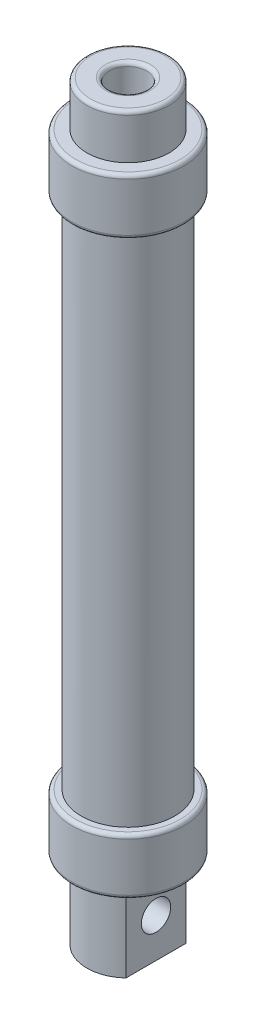
from build123d import *

# Parameters (mm, degrees)
SKETCH5_R                = 12.5
SKETCH5_R_2              = 10.5
BOSS_EXTRUDE2_DEPTH      = 140
SKETCH6_R                = 15
SKETCH6_R_2              = 11.543764588
BOSS_EXTRUDE3_DEPTH      = 14
BOSS_EXTRUDE3_DEPTH_BACK = 1
SKETCH7_R                = 15
SKETCH7_R_2              = 11.552767092
BOSS_EXTRUDE4_DEPTH      = 14
BOSS_EXTRUDE4_DEPTH_BACK = 1
FILLET1_R                = 1
FILLET2_R                = 1
FILLET3_R                = 1
FILLET4_R                = 1
SKETCH8_R                = 12.593226889
BOSS_EXTRUDE5_DEPTH      = 1
SKETCH9_R                = 12.737258032
BOSS_EXTRUDE6_DEPTH      = 1
SKETCH10_R               = 11
BOSS_EXTRUDE7_DEPTH      = 21
CUT_EXTRUDE1_DEPTH       = 21
SKETCH12_R               = 3.935
CUT_EXTRUDE2_DEPTH       = 23.5000001
SKETCH13_R               = 11
BOSS_EXTRUDE8_DEPTH      = 12
SKETCH14_R               = 5
CUT_EXTRUDE3_DEPTH       = 20
FILLET5_R                = 1
FILLET6_R                = 1


with BuildPart() as part:
    # Sketch5 → Boss-Extrude2 (new body)
    with BuildSketch(Plane(origin=(0, 0, 0), x_dir=(1, 0, 0), z_dir=(0, 1, 0))):
        Circle(SKETCH5_R)
        Circle(SKETCH5_R_2, mode=Mode.SUBTRACT)
    extrude(amount=BOSS_EXTRUDE2_DEPTH)

    # Sketch6 → Boss-Extrude3 (add, two sides)
    with BuildSketch(Plane(origin=(0, 140, 0), x_dir=(1, 0, 0), z_dir=(0, 1, 0))) as boss_extrude3_sk:
        Circle(SKETCH6_R)
        Circle(SKETCH6_R_2, mode=Mode.SUBTRACT)
    extrude(amount=BOSS_EXTRUDE3_DEPTH)
    extrude(boss_extrude3_sk.sketch, amount=-BOSS_EXTRUDE3_DEPTH_BACK)

    # Sketch7 → Boss-Extrude4 (add, two sides)
    with BuildSketch(Plane.XZ) as boss_extrude4_sk:
        Circle(SKETCH7_R)
        Circle(SKETCH7_R_2, mode=Mode.SUBTRACT)
    extrude(amount=BOSS_EXTRUDE4_DEPTH)
    extrude(boss_extrude4_sk.sketch, amount=-BOSS_EXTRUDE4_DEPTH_BACK)

    # Fillet1
    fillet1_edges = [part.edges().sort_by_distance(p)[0] for p in [
        (-15, 139, 0),
    ]]
    fillet(fillet1_edges, radius=FILLET1_R)

    # Fillet2
    fillet2_edges = [part.edges().sort_by_distance(p)[0] for p in [
        (-15, 1, 0),
    ]]
    fillet(fillet2_edges, radius=FILLET2_R)

    # Fillet3
    fillet3_edges = [part.edges().sort_by_distance(p)[0] for p in [
        (-15, 154, 0),
    ]]
    fillet(fillet3_edges, radius=FILLET3_R)

    # Fillet4
    fillet4_edges = [part.edges().sort_by_distance(p)[0] for p in [
        (-15, -14, 0),
    ]]
    fillet(fillet4_edges, radius=FILLET4_R)

    # Sketch8 → Boss-Extrude5 (add)
    with BuildSketch(Plane(origin=(0, 154, 0), x_dir=(1, 0, 0), z_dir=(0, 1, 0))):
        Circle(SKETCH8_R)
    extrude(amount=-BOSS_EXTRUDE5_DEPTH)

    # Sketch9 → Boss-Extrude6 (add)
    with BuildSketch(Plane.XZ.offset(14)):
        Circle(SKETCH9_R)
    extrude(amount=-BOSS_EXTRUDE6_DEPTH)

    # Sketch10 → Boss-Extrude7 (add)
    with BuildSketch(Plane.XZ.offset(14)):
        Circle(SKETCH10_R)
    extrude(amount=BOSS_EXTRUDE7_DEPTH)

    # Sketch11 → Cut-Extrude1 (cut)
    with BuildSketch(Plane.XZ.offset(35)):
        with BuildLine():
            Line((-7.5, 8.04673847), (-7.5, 0))
            Line((-7.5, 0), (-7.5, -8.04673847))
            ThreePointArc((-7.5, -8.04673847), (-11, 0), (-7.5, 8.04673847))
        make_face()
        with BuildLine():
            Line((7.5, 0), (7.5, -8.04673847))
            ThreePointArc((7.5, -8.04673847), (11, 0), (7.5, 8.04673847))
            Line((7.5, 8.04673847), (7.5, 0))
        make_face()
    extrude(amount=-CUT_EXTRUDE1_DEPTH, mode=Mode.SUBTRACT)

    # Sketch12 → Cut-Extrude2 (cut, through all)
    with BuildSketch(Plane.ZY.offset(7.5)):
        with Locations((0, -24.5)):
            Circle(SKETCH12_R)
    extrude(amount=-CUT_EXTRUDE2_DEPTH, mode=Mode.SUBTRACT)

    # Sketch13 → Boss-Extrude8 (add)
    with BuildSketch(Plane(origin=(0, 154, 0), x_dir=(1, 0, 0), z_dir=(0, 1, 0))):
        Circle(SKETCH13_R)
    extrude(amount=BOSS_EXTRUDE8_DEPTH)

    # Sketch14 → Cut-Extrude3 (cut)
    with BuildSketch(Plane(origin=(0, 166, 0), x_dir=(1, 0, 0), z_dir=(0, 1, 0))):
        Circle(SKETCH14_R)
    extrude(amount=-CUT_EXTRUDE3_DEPTH, mode=Mode.SUBTRACT)

    # Fillet5
    fillet5_edges = [part.edges().sort_by_distance(p)[0] for p in [
        (-11, 166, 0),
    ]]
    fillet(fillet5_edges, radius=FILLET5_R)

    # Fillet6
    fillet6_edges = [part.edges().sort_by_distance(p)[0] for p in [
        (-5, 166, 0),
    ]]
    fillet(fillet6_edges, radius=FILLET6_R)


solid = part.part
